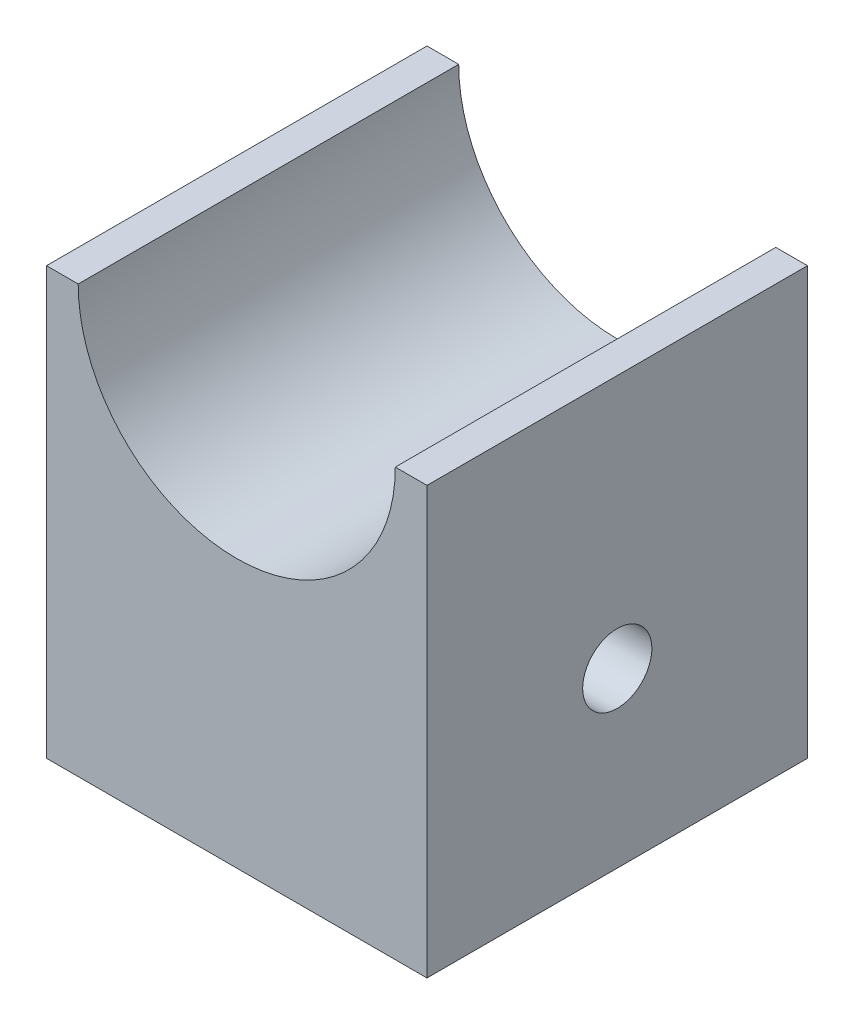
from build123d import *

# Parameters (mm, degrees)
SKETCH1_W           = 33
SKETCH1_H           = 37
BOSS_EXTRUDE1_DEPTH = 33
SKETCH2_R           = 13.75
CUT_EXTRUDE1_DEPTH  = 33
SKETCH3_R           = 3
CUT_EXTRUDE2_DEPTH  = 33


with BuildPart() as part:
    # Sketch1 → Boss-Extrude1 (new body)
    with BuildSketch(Plane.XY):
        with Locations((-16.5, 18.5)):
            Rectangle(SKETCH1_W, SKETCH1_H)
    extrude(amount=BOSS_EXTRUDE1_DEPTH)

    # Sketch2 → Cut-Extrude1 (cut)
    with BuildSketch(Plane.XY.offset(33)):
        with Locations((-16.5, 37)):
            Circle(SKETCH2_R)
    extrude(amount=-CUT_EXTRUDE1_DEPTH, mode=Mode.SUBTRACT)

    # Sketch3 → Cut-Extrude2 (cut)
    with BuildSketch(Plane.ZY.offset(33)):
        with Locations((16.5, 15)):
            Circle(SKETCH3_R)
    extrude(amount=-CUT_EXTRUDE2_DEPTH, mode=Mode.SUBTRACT)


solid = part.part
